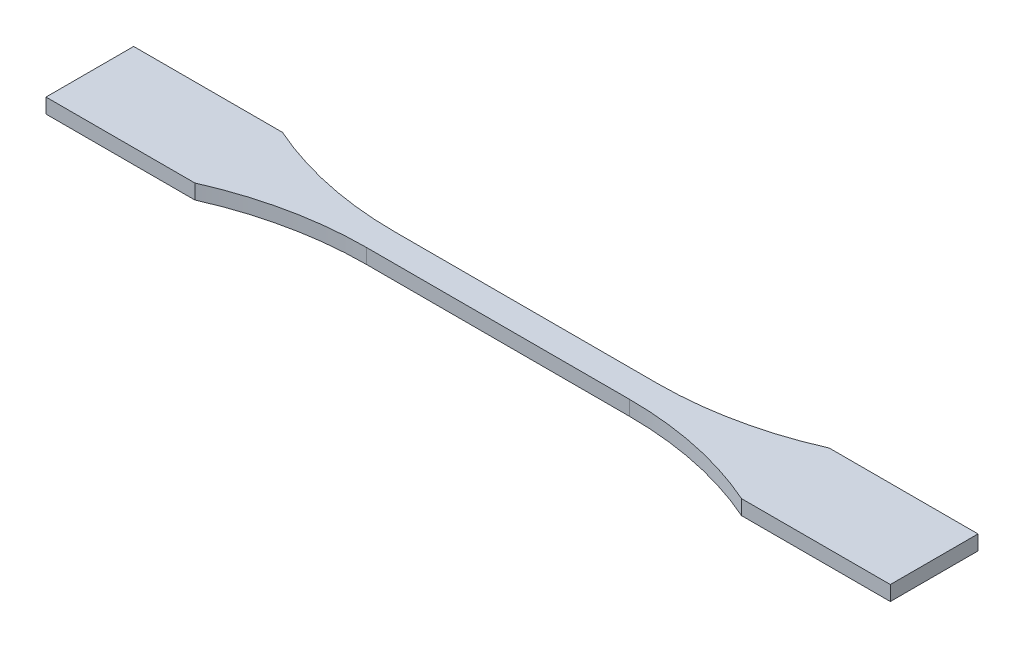
from build123d import *

# Parameters (mm, degrees)
CROQUIS1_W              = 57
CROQUIS1_H              = 6
SALIENTE_EXTRUIR1_DEPTH = 1.6


with BuildPart() as part:
    # Croquis1 → Saliente-Extruir1 (new body, symmetric)
    with BuildSketch(Plane(origin=(0, 0, 0), x_dir=(1, 0, 0), z_dir=(0, 1, 0))):
        with BuildLine():
            Line((-91.5, -9.5), (-59.253048629, -9.5))
            ThreePointArc((-59.253048629, -9.5), (-44.216233646, -4.64275422), (-28.5, -3))
            Line((-28.5, -3), (-28.5, 3))
            ThreePointArc((-28.5, 3), (-44.216233646, 4.64275422), (-59.253048629, 9.5))
            Line((-59.253048629, 9.5), (-91.5, 9.5))
            Line((-91.5, 9.5), (-91.5, -9.5))
        make_face()
        with BuildLine():
            Line((59.253048629, -9.5), (91.5, -9.5))
            Line((91.5, -9.5), (91.5, 9.5))
            Line((91.5, 9.5), (59.253048629, 9.5))
            ThreePointArc((59.253048629, 9.5), (44.216233646, 4.64275422), (28.5, 3))
            Line((28.5, 3), (28.5, -3))
            ThreePointArc((28.5, -3), (44.216233646, -4.64275422), (59.253048629, -9.5))
        make_face()
        Rectangle(CROQUIS1_W, CROQUIS1_H)
    extrude(amount=SALIENTE_EXTRUIR1_DEPTH, both=True)


solid = part.part
